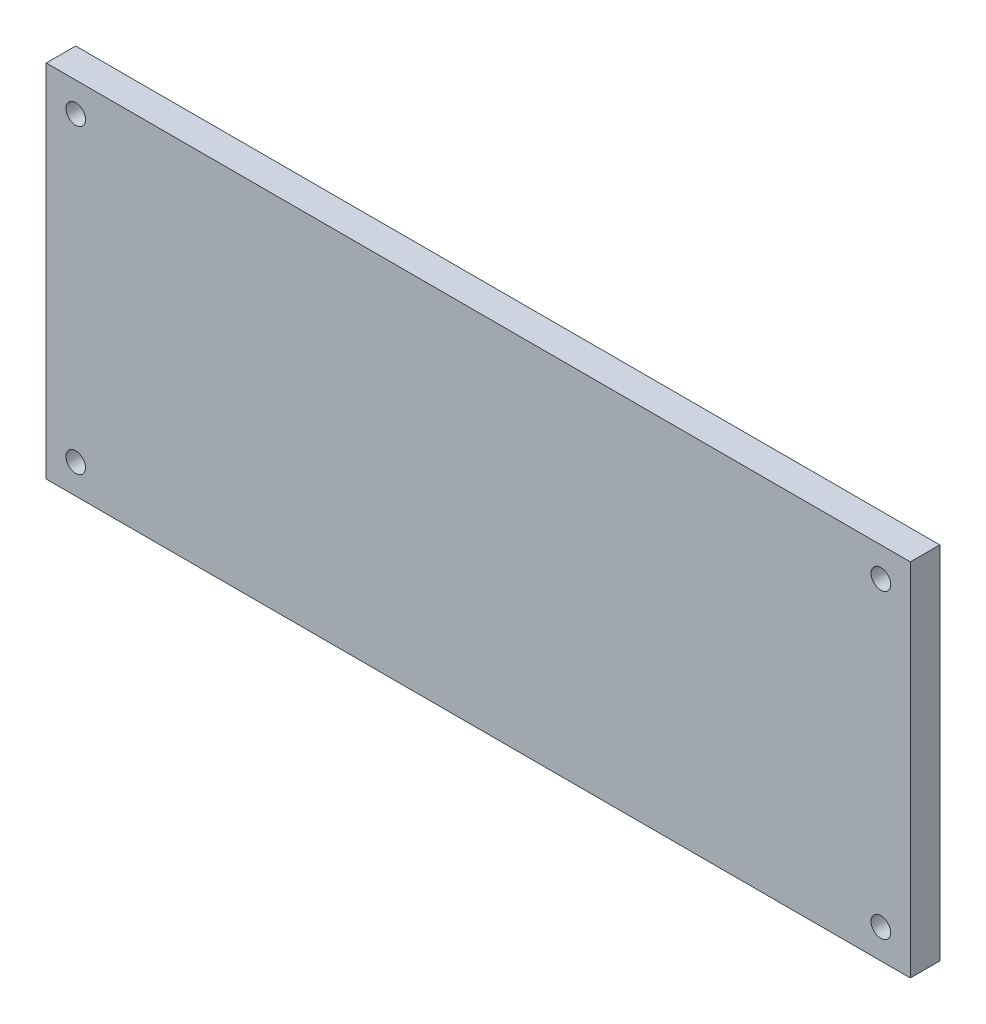
from build123d import *

# Parameters (mm, degrees)
SKETCH_1_W      = 44
SKETCH_1_H      = 18.35
SKETCH_1_R      = 0.5
EXTRUDE_1_DEPTH = 1.5


with BuildPart() as part:
    # Эскиз1 → Бобышка-Вытянуть1 (new body)
    with BuildSketch(Plane.XY):
        with Locations((22, 9.175)):
            Rectangle(SKETCH_1_W, SKETCH_1_H)
        with Locations((1.5, 16.85)):
            Circle(SKETCH_1_R, mode=Mode.SUBTRACT)
        with Locations((42.5, 16.85)):
            Circle(SKETCH_1_R, mode=Mode.SUBTRACT)
        with Locations((42.5, 1.5)):
            Circle(SKETCH_1_R, mode=Mode.SUBTRACT)
        with Locations((1.5, 1.5)):
            Circle(SKETCH_1_R, mode=Mode.SUBTRACT)
    extrude(amount=EXTRUDE_1_DEPTH)


solid = part.part
